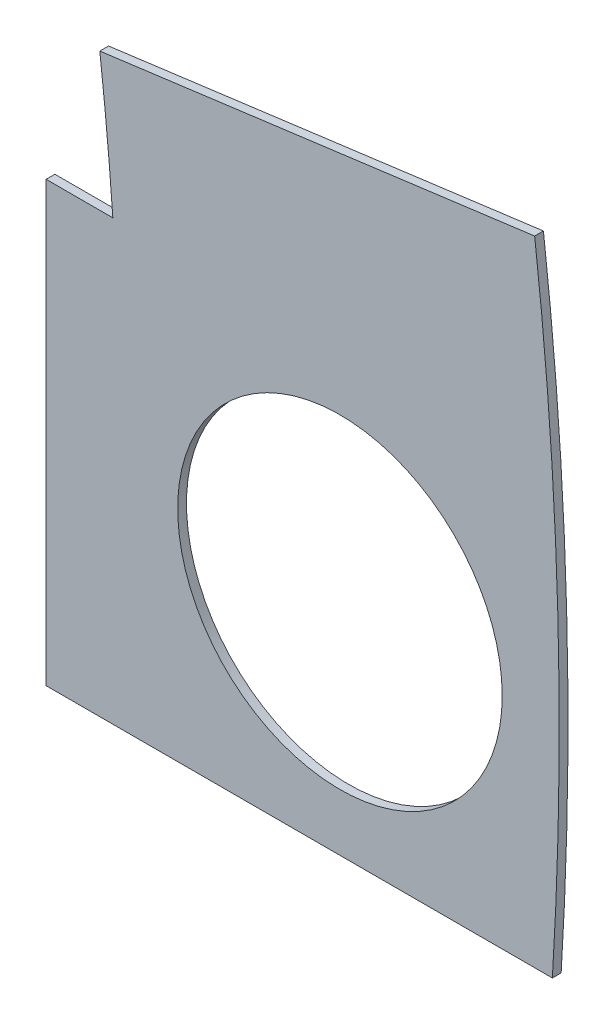
from build123d import *

# Parameters (mm, degrees)
BOSS_EXTRUDE1_DEPTH = 0.254
SKETCH2_R           = 4.699
CUT_EXTRUDE1_DEPTH  = 1.254
SKETCH3_W           = 2.54
SKETCH3_H           = 0.635
CUT_EXTRUDE2_DEPTH  = 1.254
SKETCH5_OUTSIDE_W   = 121.447
SKETCH5_OUTSIDE_H   = 109.618
CUT_EXTRUDE5_DEPTH  = 1.254


with BuildPart() as part:
    # Sketch1 → Boss-Extrude1 (new body)
    with BuildSketch(Plane.XY):
        with BuildLine():
            Line((67.21146711, 76.191723231), (8.696654013, 17.676910134))
            Line((8.696654013, 17.676910134), (7.228954972, 14.133571205))
            ThreePointArc((7.228954972, 14.133571205), (14.666587579, 6.075099489), (15.105587123, -4.88230096))
            Line((15.105587123, -4.88230096), (18.648926052, -6.35))
            Line((18.648926052, -6.35), (101.401368334, -6.35))
            ThreePointArc((101.401368334, -6.35), (93.866160503, 38.880636728), (67.21146711, 76.191723231))
        make_face()
        with BuildLine():
            Line((88.672924278, 6.35), (27.86051193, 6.35))
            ThreePointArc((27.86051193, 6.35), (26.399857642, 10.93517908), (24.190484974, 15.210228852))
            Line((24.190484974, 15.210228852), (67.191354125, 58.211098004))
            ThreePointArc((67.191354125, 58.211098004), (82.13289044, 34.020557137), (88.672924278, 6.35))
        make_face(mode=Mode.SUBTRACT)
    extrude(amount=BOSS_EXTRUDE1_DEPTH)

    # Sketch2 → Cut-Extrude1 (cut, through all)
    with BuildSketch(Plane.XY.offset(0.254)):
        with Locations((22.225, 0)):
            Circle(SKETCH2_R)
        with Locations((36.195, 0)):
            Circle(SKETCH2_R)
        with Locations((61.722, 0)):
            Circle(SKETCH2_R)
        with Locations((75.692, 0)):
            Circle(SKETCH2_R)
        with Locations((95.25, 0)):
            Circle(SKETCH2_R)
        with Locations((15.715448212, 15.715448212)):
            Circle(SKETCH2_R)
        with Locations((25.593729945, 25.593729945)):
            Circle(SKETCH2_R)
        with Locations((43.644044748, 43.644044748)):
            Circle(SKETCH2_R)
        with Locations((53.522326482, 53.522326482)):
            Circle(SKETCH2_R)
        with Locations((92.004434954, 24.652514046)):
            Circle(SKETCH2_R)
        with Locations((82.48891971, 47.625)):
            Circle(SKETCH2_R)
        with Locations((67.351920908, 67.351920908)):
            Circle(SKETCH2_R)
    extrude(amount=-CUT_EXTRUDE1_DEPTH, mode=Mode.SUBTRACT)

    # Sketch3 → Cut-Extrude2 (cut, through all)
    with BuildSketch(Plane.XY.offset(0.254)):
        Polygon((15.266435406, 24.246691527), (17.06248663, 26.042742751), (17.511499436, 25.593729945), (15.715448212, 23.797678721), align=None)
        Polygon((44.991083167, 53.971339288), (43.195031942, 52.175288063), (43.644044748, 51.726275257), (45.440095973, 53.522326482), align=None)
        with Locations((29.21, -6.0325)):
            Rectangle(SKETCH3_W, SKETCH3_H)
        with Locations((68.707, -6.0325)):
            Rectangle(SKETCH3_W, SKETCH3_H)
        Polygon((29.230733674, 38.210989795), (31.026784898, 40.007041019), (31.475797704, 39.558028213), (29.67974648, 37.761976989), align=None)
        Polygon((56.845021246, 65.825277367), (55.048970022, 64.029226143), (55.497982828, 63.580213337), (57.294034052, 65.376264561), align=None)
        with Locations((48.9585, -6.0325)):
            Rectangle(SKETCH3_W, SKETCH3_H)
        with Locations((85.471, -6.0325)):
            Rectangle(SKETCH3_W, SKETCH3_H)
        Polygon((99.935462164, 14.437711971), (100.266998693, 11.919442024), (101.526133667, 12.085210288), (101.194597138, 14.603480236), align=None)
        Polygon((93.765504959, 37.464305742), (94.938831965, 37.950313702), (93.966816047, 40.296967714), (92.793489041, 39.810959755), align=None)
        Polygon((79.327792988, 62.471156422), (80.874047017, 60.456038938), (81.88160576, 61.229165953), (80.33535173, 63.244283437), align=None)
        Polygon((13.593916116, 7.005422516), (14.565932035, 4.658768503), (15.739259041, 5.144776462), (14.767243123, 7.491430475), align=None)
    extrude(amount=-CUT_EXTRUDE2_DEPTH, mode=Mode.SUBTRACT)

    # Sketch5 outside → Cut-Extrude5 (cut, through all)
    with BuildSketch(Plane.XY.offset(0.254)):
        with Locations((54.4145, 34.921)):
            Rectangle(SKETCH5_OUTSIDE_W, SKETCH5_OUTSIDE_H)
        Polygon((86.741, -7.62), (86.741, 10.138710513), (102.87, 12.262133647), (102.87, -7.62), align=None, mode=Mode.SUBTRACT)
    extrude(amount=-CUT_EXTRUDE5_DEPTH, mode=Mode.SUBTRACT)


solid = part.part
